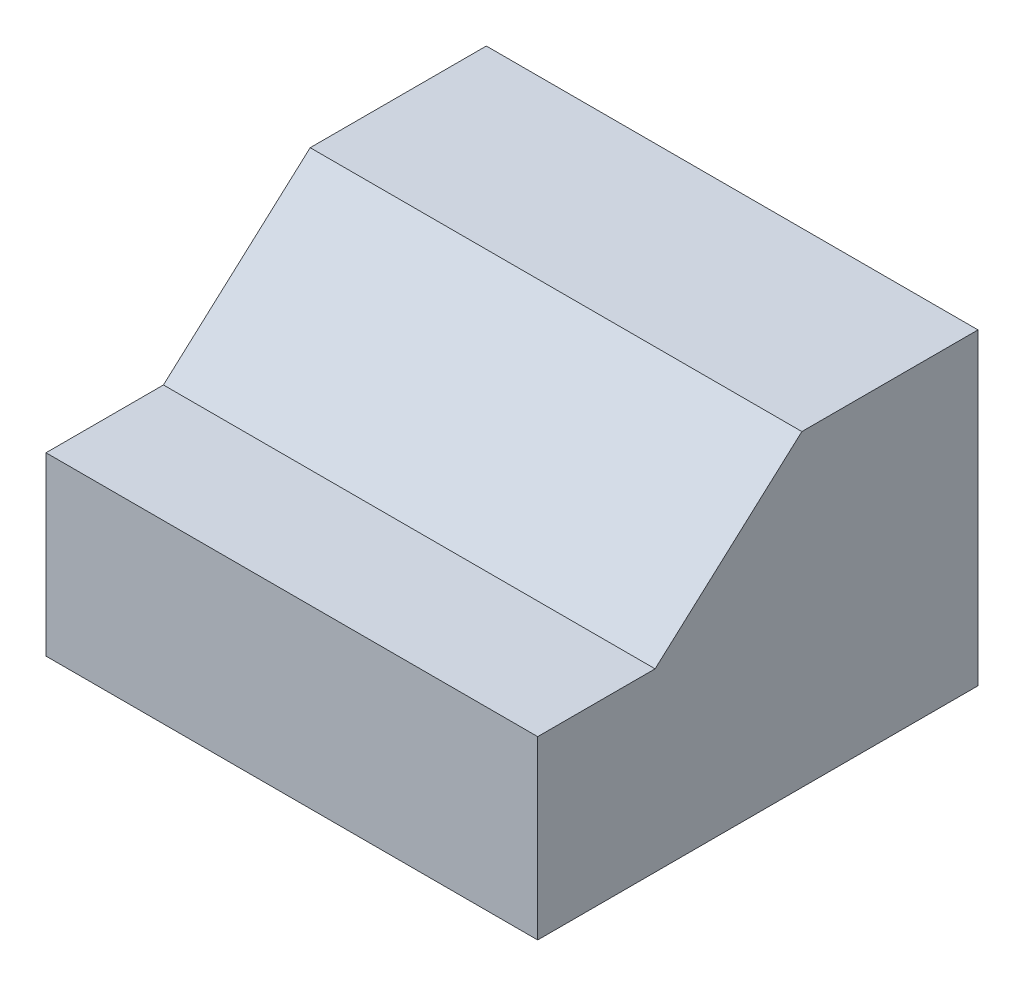
from build123d import *

# Parameters (mm, degrees)
BOSS_EXTRUDE1_DEPTH = 850.9


with BuildPart() as part:
    # Sketch1 → Boss-Extrude1 (new body, symmetric)
    with BuildSketch(Plane(origin=(0, 0, 0), x_dir=(0, 0, -1), z_dir=(1, 0, 0))):
        Polygon((0, 0), (-406.4, 0), (-406.4, -609.6), (1117.6, -609.6), (1117.6, 457.2), (508, 457.2), align=None)
    extrude(amount=BOSS_EXTRUDE1_DEPTH, both=True)


solid = part.part
